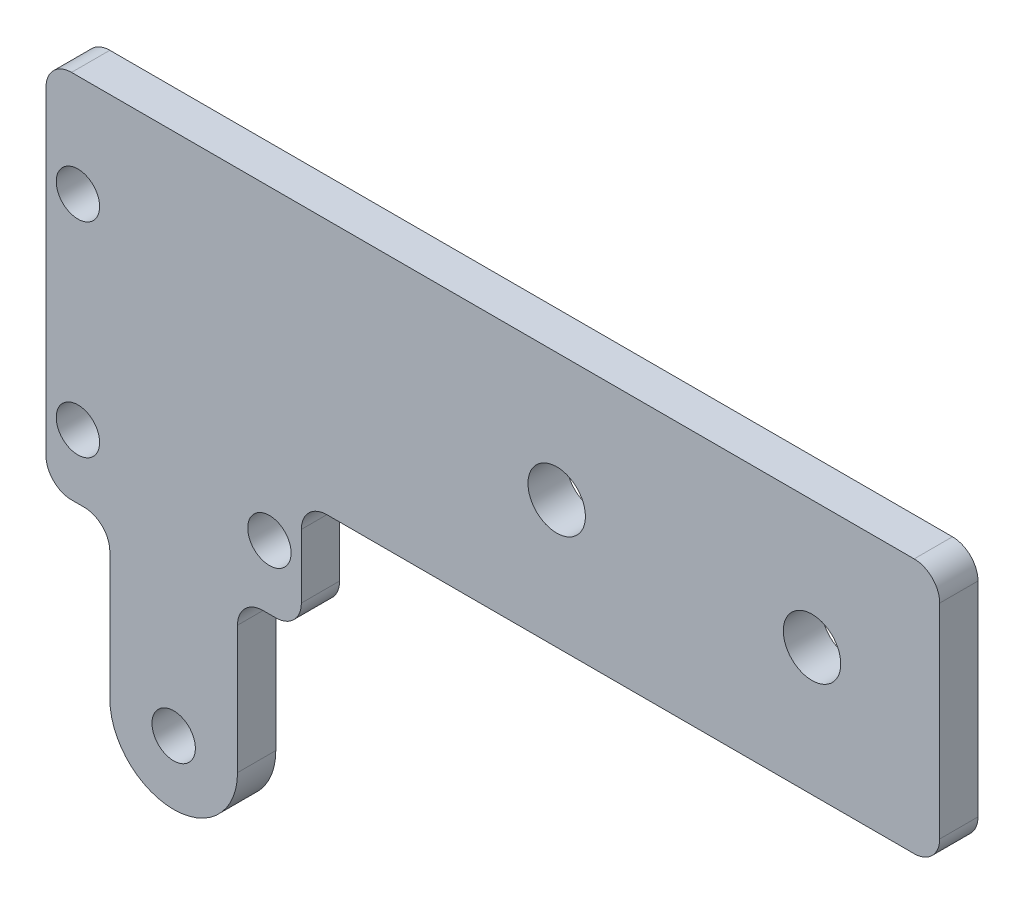
from build123d import *

# Parameters (mm, degrees)
AUFSATZ_LINEAR_AUSTRAGEN1_DEPTH = 3
SKIZZE2_R                       = 1.7
SCHNITT_LINEAR_AUSTRAGEN1_DEPTH = 4
DURCHGANGSLOCH_F_R_M41_D        = 4.5
DURCHGANGSLOCH_F_R_M31_D        = 3.4
VERRUNDUNG1_R                   = 2


with BuildPart() as part:
    # Skizze1 → Aufsatz-Linear austragen1 (new body)
    with BuildSketch(Plane.XY):
        with BuildLine():
            Line((0, 0), (0, -9))
            Line((0, -9), (-5, -9))
            Line((-5, -9), (-5, -21))
            ThreePointArc((-5, -21), (-10, -26), (-15, -21))
            Line((-15, -21), (-15, -9))
            Line((-15, -9), (-20, -9))
            Line((-20, -9), (-20, 20))
            Line((-20, 20), (50, 20))
            Line((50, 20), (50, 0))
            Line((50, 0), (0, 0))
        make_face()
    extrude(amount=AUFSATZ_LINEAR_AUSTRAGEN1_DEPTH)

    # Skizze2 → Schnitt-Linear austragen1 (cut, through all)
    with BuildSketch(Plane.XY.offset(3)):
        with Locations((-10, -21)):
            Circle(SKIZZE2_R)
    extrude(amount=-SCHNITT_LINEAR_AUSTRAGEN1_DEPTH, mode=Mode.SUBTRACT)

    # Durchgangsloch für M41 (through all)
    with Locations(Plane.XY.offset(3)):
        with Locations((20, 10), (40, 10)):
            Hole(DURCHGANGSLOCH_F_R_M41_D / 2)

    # Durchgangsloch für M31 (through all)
    with Locations(Plane.XY.offset(3)):
        with Locations((-17.5, 12), (-2.5, -4), (-17.5, -4)):
            Hole(DURCHGANGSLOCH_F_R_M31_D / 2)

    # Verrundung1
    verrundung1_edges = [part.edges().sort_by_distance(p)[0] for p in [
        (0, 0, 1.5),
        (0, -9, 1.5),
        (-5, -9, 1.5),
        (-15, -9, 1.5),
        (-20, -9, 1.5),
        (-20, 20, 1.5),
        (50, 20, 1.5),
        (50, 0, 1.5),
    ]]
    fillet(verrundung1_edges, radius=VERRUNDUNG1_R)


solid = part.part
